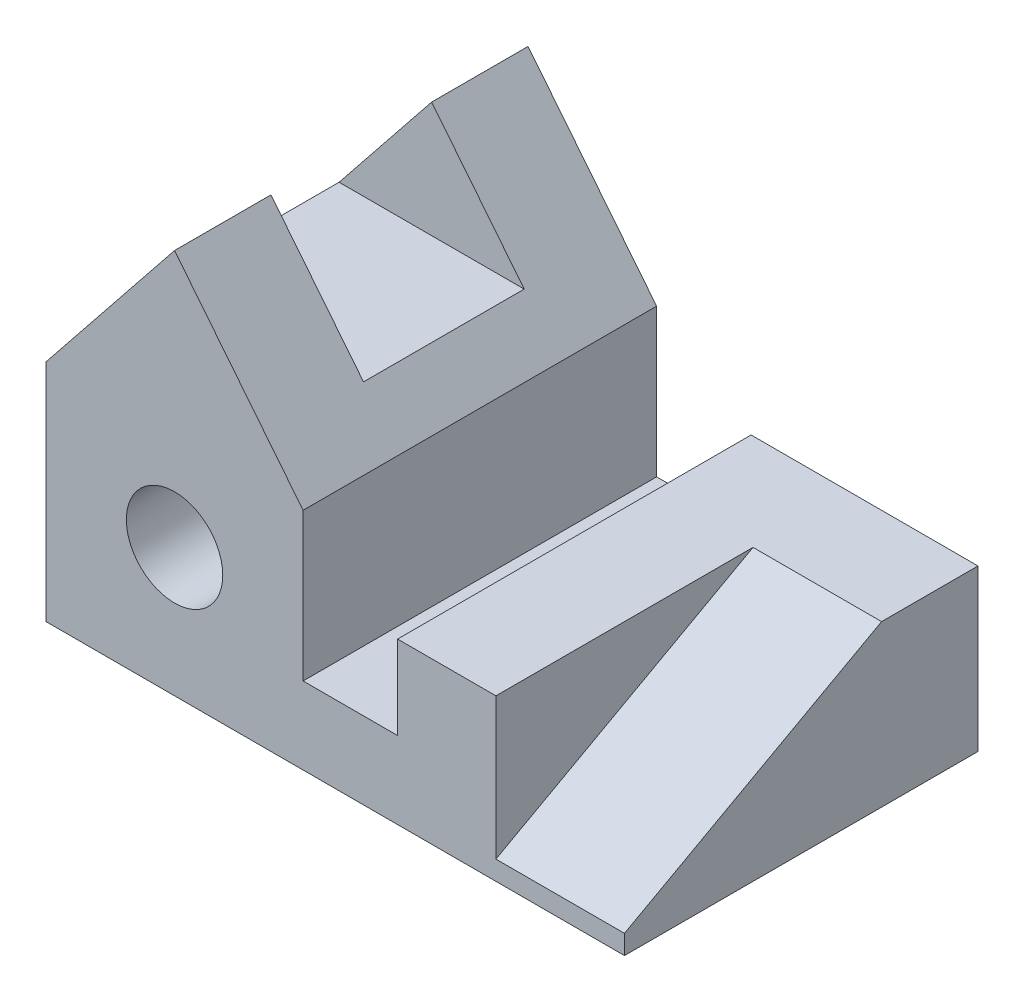
from build123d import *

# Parameters (mm, degrees)
SKETCH1_W               = 2286
SKETCH1_H               = 1397
BOSS_EXTRUDE1_DEPTH     = 1524
CUT_EXTRUDE7_DEPTH      = 1
CUT_EXTRUDE7_DEPTH_BACK = 1397
SKETCH3_R               = 190.5
CUT_EXTRUDE8_DEPTH      = 1398
CUT_EXTRUDE9_DEPTH      = 317.5
CUT_EXTRUDE9_DEPTH_BACK = 317.5
CUT_EXTRUDE10_DEPTH     = 508


with BuildPart() as part:
    # Sketch1 → Boss-Extrude1 (new body)
    with BuildSketch(Plane(origin=(0, 0, 0), x_dir=(1, 0, 0), z_dir=(0, 1, 0))):
        Rectangle(SKETCH1_W, SKETCH1_H)
    extrude(amount=BOSS_EXTRUDE1_DEPTH)

    # Sketch2 → Cut-Extrude7 (cut, two sides)
    with BuildSketch(Plane.XY.offset(698.5)) as cut_extrude7_sk:
        Polygon((-4213.722746177, -2949.403432721), (-1143, 889), (-635, 1524), (-127, 889), (-127, 304.8), (246.405498816, 304.8), (246.405498816, 635), (1143, 635), (6058.55481062, 635), (2819.614537591, 9917.240154866), (-7452.663019206, 6332.836722145), align=None)
    extrude(amount=CUT_EXTRUDE7_DEPTH, mode=Mode.SUBTRACT)
    extrude(cut_extrude7_sk.sketch, amount=-CUT_EXTRUDE7_DEPTH_BACK, mode=Mode.SUBTRACT)

    # Sketch3 → Cut-Extrude8 (cut, through all)
    with BuildSketch(Plane.XY.offset(698.5)):
        with Locations((-635, 508)):
            Circle(SKETCH3_R)
    extrude(amount=-CUT_EXTRUDE8_DEPTH, mode=Mode.SUBTRACT)

    # Sketch8 → Cut-Extrude9 (cut, two sides)
    with BuildSketch(Plane.XY) as cut_extrude9_sk:
        Polygon((-635, 1066.8), (-1000.76, 1066.8), (-635, 1524), (-269.24, 1066.8), align=None)
    extrude(amount=CUT_EXTRUDE9_DEPTH, mode=Mode.SUBTRACT)
    extrude(cut_extrude9_sk.sketch, amount=-CUT_EXTRUDE9_DEPTH_BACK, mode=Mode.SUBTRACT)

    # Sketch9 → Cut-Extrude10 (cut)
    with BuildSketch(Plane(origin=(1143, 0, 0), x_dir=(0, 0, -1), z_dir=(1, 0, 0))):
        Polygon((317.5, 635), (-698.5, 76.2), (-698.5, 635), align=None)
    extrude(amount=-CUT_EXTRUDE10_DEPTH, mode=Mode.SUBTRACT)


solid = part.part
